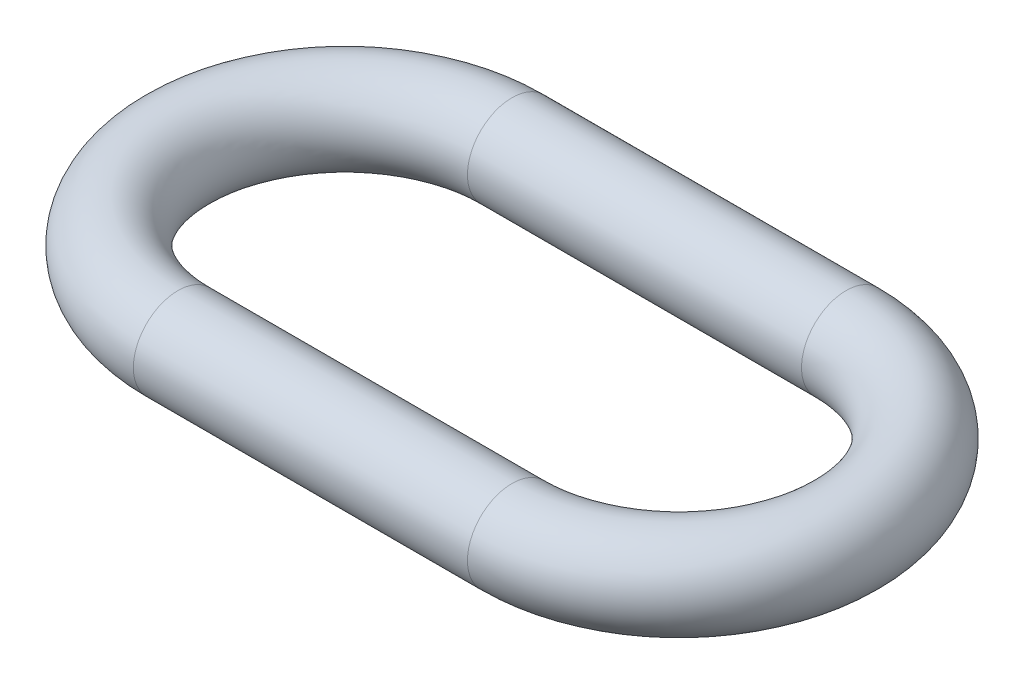
from build123d import *

# Parameters (mm, degrees)
SKETCH5_R = 2


with BuildPart() as part:
    # Sweep4: sweep along a path in Sketch1
    with BuildLine(Plane(origin=(0, 0, 0), x_dir=(1, 0, 0), z_dir=(0, 1, 0))) as sweep4_path:
        Line((-28.610205965, -7.5), (-43.610205965, -7.5))
        ThreePointArc((-43.610205965, -7.5), (-51.110205965, 0), (-43.610205965, 7.5))
        Line((-43.610205965, 7.5), (-28.610205965, 7.5))
        ThreePointArc((-28.610205965, 7.5), (-21.110205965, 0), (-28.610205965, -7.5))
    # Sketch5 → Sweep4 (sweep)
    with BuildSketch(Plane.XY):
        with Locations((-21.110205965, 0)):
            Circle(SKETCH5_R)
    sweep(path=sweep4_path.line)


solid = part.part
